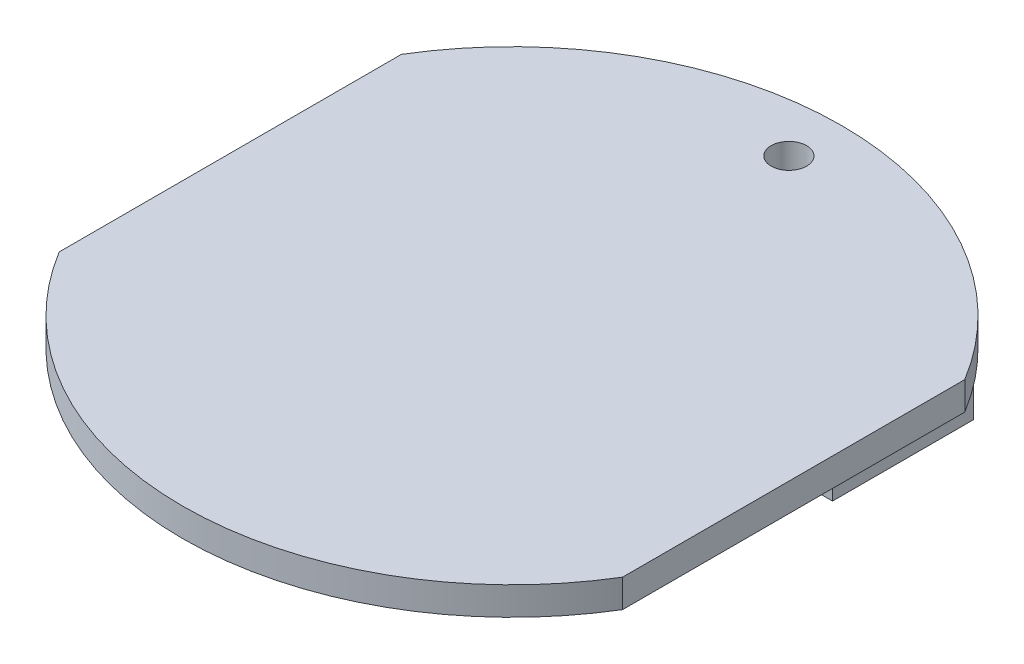
from build123d import *

# Parameters (mm, degrees)
SKETCH_2_R          = 12
SKETCH_1_R          = 12.5
CUT_EXTRUDE_1_DEPTH = 12.0000001
SKETCH_5_W          = 13
SKETCH_5_H          = 6
CUT_EXTRUDE_2_DEPTH = 5
SKETCH_6_W          = 2.476692414
SKETCH_6_H          = 6.83521307
CUT_EXTRUDE_3_DEPTH = 20
CUT_EXTRUDE_4_DEPTH = 5
SKETCH_9_R          = 0.630926361
EXTRUDE_1_DEPTH     = 1
SKETCH_11_W         = 27.446294714
SKETCH_11_H         = 11.793449851
CUT_EXTRUDE_5_DEPTH = 21.75
SKETCH_10_W         = 3.891529141
SKETCH_10_H         = 5
EXTRUDE_2_DEPTH     = 2.5


with BuildPart() as part:
    # 草图2 → 放样1 section 0
    with BuildSketch(Plane(origin=(0, 11, 0), x_dir=(1, 0, 0), z_dir=(0, 1, 0))):
        Circle(SKETCH_2_R)
    # 草图1 → 放样1 section 1
    with BuildSketch(Plane(origin=(0, 0, 0), x_dir=(1, 0, 0), z_dir=(0, 1, 0))):
        Circle(SKETCH_1_R)
    loft()

    # 草图4 → 切除-拉伸1 (cut, through all)
    with BuildSketch(Plane(origin=(0, 0, 0), x_dir=(1, 0, 0), z_dir=(0, 1, 0))):
        with BuildLine():
            Line((-1.352272566, -2.5), (-1.352272566, -2.102702762))
            ThreePointArc((-1.352272566, -2.102702762), (0.025010963, 2.499874887), (1.309931483, -2.12933781))
            Line((1.309931483, -2.12933781), (1.309931483, -2.5))
            Line((1.309931483, -2.5), (8, -2.5))
            Line((8, -2.5), (8, -7.5))
            Line((8, -7.5), (-8, -7.5))
            Line((-8, -7.5), (-8, -2.5))
            Line((-8, -2.5), (-1.352272566, -2.5))
        make_face()
    extrude(amount=CUT_EXTRUDE_1_DEPTH, mode=Mode.SUBTRACT)

    # 草图5 → 切除-拉伸2 (cut)
    with BuildSketch(Plane(origin=(0, 11, 0), x_dir=(1, 0, 0), z_dir=(0, 1, 0))):
        with Locations((0, 5.991032562)):
            Rectangle(SKETCH_5_W, SKETCH_5_H)
        with BuildLine():
            Line((7.947410488, 8.991032562), (6.5, 8.991032562))
            Line((6.5, 8.991032562), (6.5, 2.991032562))
            Line((6.5, 2.991032562), (11.621261731, 2.991032562))
            ThreePointArc((11.621261731, 2.991032562), (10.233925596, 6.266320045), (7.947410488, 8.991032562))
        make_face()
        with BuildLine():
            Line((15.348611284, 8.991032562), (7.947410488, 8.991032562))
            ThreePointArc((7.947410488, 8.991032562), (10.233925596, 6.266320045), (11.621261731, 2.991032562))
            Line((11.621261731, 2.991032562), (15.348611284, 2.991032562))
            Line((15.348611284, 2.991032562), (15.348611284, 8.991032562))
        make_face()
    extrude(amount=-CUT_EXTRUDE_2_DEPTH, mode=Mode.SUBTRACT)

    # 草图6 → 切除-拉伸3 (cut, symmetric)
    with BuildSketch(Plane(origin=(0, 0, 0), x_dir=(0, 0, -1), z_dir=(1, 0, 0))):
        with Locations((0, 8.790545757)):
            Rectangle(SKETCH_6_W, SKETCH_6_H)
    extrude(amount=CUT_EXTRUDE_3_DEPTH, both=True, mode=Mode.SUBTRACT)

    # 草图7 → 切除-拉伸4 (cut)
    with BuildSketch(Plane(origin=(0, 11, 0), x_dir=(1, 0, 0), z_dir=(0, 1, 0))):
        Polygon((-5.998196858, 2.991032562), (-5.998196858, -3.96939498), (-8, -3.96939498), (-9.46939498, -2.5), (-9.46939498, 3.910589128), (-7.645587141, 5.734396966), (-6.5, 5.734396966), align=None)
    extrude(amount=-CUT_EXTRUDE_4_DEPTH, mode=Mode.SUBTRACT)

    # 草图9 → 凸台-拉伸1 (add)
    with BuildSketch(Plane(origin=(0, 11, 0), x_dir=(1, 0, 0), z_dir=(0, 1, 0))):
        with BuildLine():
            Line((-10, 6.073713856), (-10, -6.073713856))
            ThreePointArc((-10, -6.073713856), (0, -11.7), (10, -6.073713856))
            Line((10, -6.073713856), (10, 6.073713856))
            ThreePointArc((10, 6.073713856), (0, 11.7), (-10, 6.073713856))
        make_face()
        with Locations((0, 9.829977892)):
            Circle(SKETCH_9_R, mode=Mode.SUBTRACT)
    extrude(amount=EXTRUDE_1_DEPTH)

    # 草图11 → 切除-拉伸5 (cut, symmetric)
    with BuildSketch(Plane(origin=(0, 0, 0), x_dir=(0, 0, -1), z_dir=(1, 0, 0))):
        with Locations((-0.090881771, 5.103275074)):
            Rectangle(SKETCH_11_W, SKETCH_11_H)
    extrude(amount=CUT_EXTRUDE_5_DEPTH, both=True, mode=Mode.SUBTRACT)

    # 草图10 → 凸台-拉伸2 (add)
    with BuildSketch(Plane.XZ.offset(-11)):
        with Locations((5.943222156, -5.991032562)):
            Rectangle(SKETCH_10_W, SKETCH_10_H)
    extrude(amount=EXTRUDE_2_DEPTH)


solid = part.part
